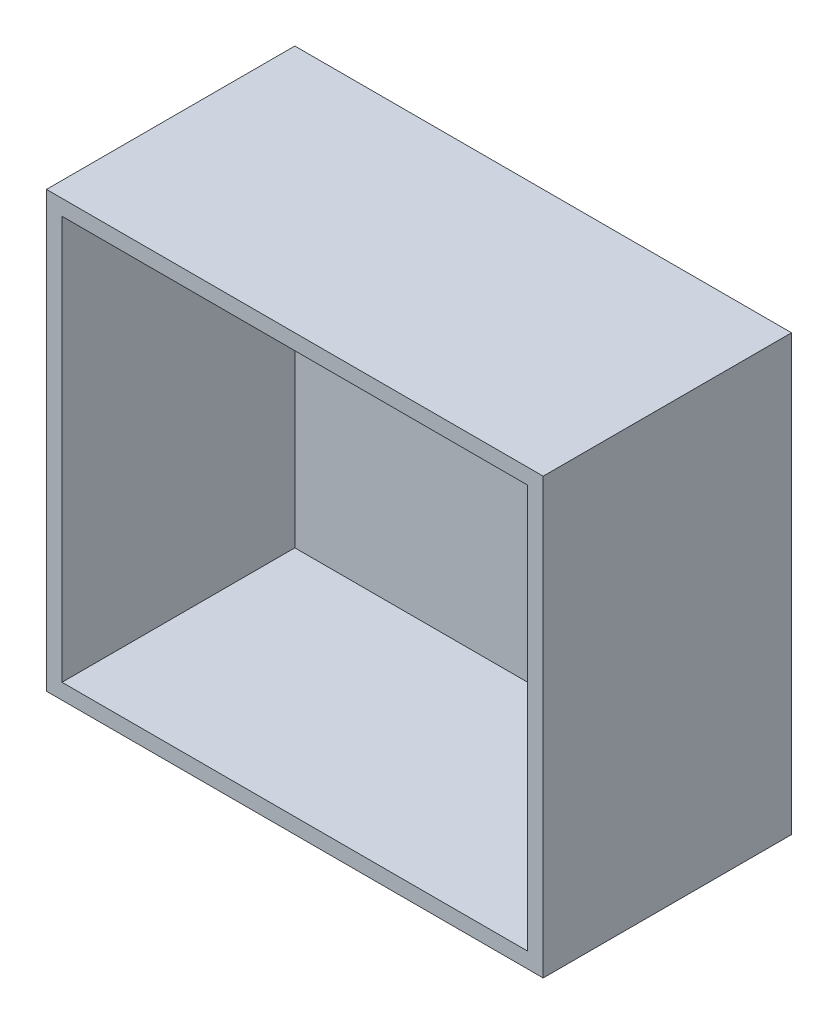
from build123d import *

# Parameters (mm, degrees)
SKETCH1_W           = 64
SKETCH1_H           = 56
BOSS_EXTRUDE1_DEPTH = 32
SKETCH3_W           = 60
SKETCH3_H           = 52
CUT_EXTRUDE1_DEPTH  = 30


with BuildPart() as part:
    # Sketch1 → Boss-Extrude1 (new body)
    with BuildSketch(Plane.XY):
        with Locations((32, 28)):
            Rectangle(SKETCH1_W, SKETCH1_H)
    extrude(amount=BOSS_EXTRUDE1_DEPTH)

    # Sketch3 → Cut-Extrude1 (cut)
    with BuildSketch(Plane.XY.offset(32)):
        with Locations((32, 28)):
            Rectangle(SKETCH3_W, SKETCH3_H)
    extrude(amount=-CUT_EXTRUDE1_DEPTH, mode=Mode.SUBTRACT)


solid = part.part
